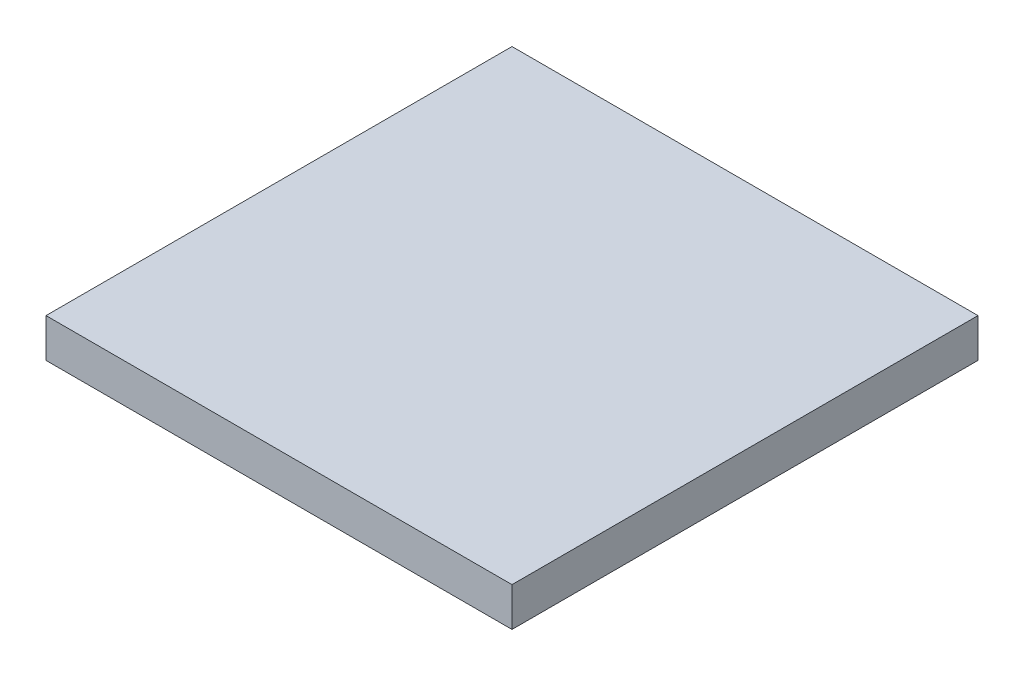
from build123d import *

# Parameters (mm, degrees)
IZIM1_W                     = 23.88
IZIM1_H                     = 10.92
Y_KSEKLIK_EKSTR_ZYON5_DEPTH = 10
IZIM4_W                     = 60
IZIM4_H                     = 60
Y_KSEKLIK_EKSTR_ZYON6_DEPTH = 5
IZIM5_R                     = 1
KES_EKSTR_ZYON1_DEPTH       = 3
IZIM6_R                     = 1
KES_EKSTR_ZYON2_DEPTH       = 3
L_EK1_SCALE                 = 0.5


with BuildPart() as part:
    # Çizim1 → Yükseklik-Ekstrüzyon5 (new body)
    with BuildSketch(Plane(origin=(0, 0, 0), x_dir=(1, 0, 0), z_dir=(0, 1, 0))):
        Rectangle(IZIM1_W, IZIM1_H)
    extrude(amount=Y_KSEKLIK_EKSTR_ZYON5_DEPTH)

    # Çizim4 → Yükseklik-Ekstrüzyon6 (add)
    with BuildSketch(Plane(origin=(0, 10, 0), x_dir=(1, 0, 0), z_dir=(0, 1, 0))):
        Rectangle(IZIM4_W, IZIM4_H)
    extrude(amount=Y_KSEKLIK_EKSTR_ZYON6_DEPTH)

    # Çizim5 → Kes-Ekstrüzyon1 (cut)
    with BuildSketch(Plane.XY.offset(5.46)):
        with Locations((9.64, 2.25)):
            Circle(IZIM5_R)
        with Locations((9.64, 6.75)):
            Circle(IZIM5_R)
        with Locations((-9.64, 6.75)):
            Circle(IZIM5_R)
        with Locations((-9.64, 2.25)):
            Circle(IZIM5_R)
    extrude(amount=-KES_EKSTR_ZYON1_DEPTH, mode=Mode.SUBTRACT)

    # Çizim6 → Kes-Ekstrüzyon2 (cut)
    with BuildSketch(Plane(origin=(0, 0, -5.46), x_dir=(-1, 0, 0), z_dir=(0, 0, -1))):
        with Locations((9.64, 2.25)):
            Circle(IZIM6_R)
        with Locations((9.64, 6.75)):
            Circle(IZIM6_R)
        with Locations((-9.64, 6.75)):
            Circle(IZIM6_R)
        with Locations((-9.64, 2.25)):
            Circle(IZIM6_R)
    extrude(amount=-KES_EKSTR_ZYON2_DEPTH, mode=Mode.SUBTRACT)


with BuildPart() as part_1:
    # Ölçek1: scaled about (0, 11.57684301, 0)
    add(part.part.scale(L_EK1_SCALE).moved(Location((0, 5.788421505, 0))))


solid = part_1.part
